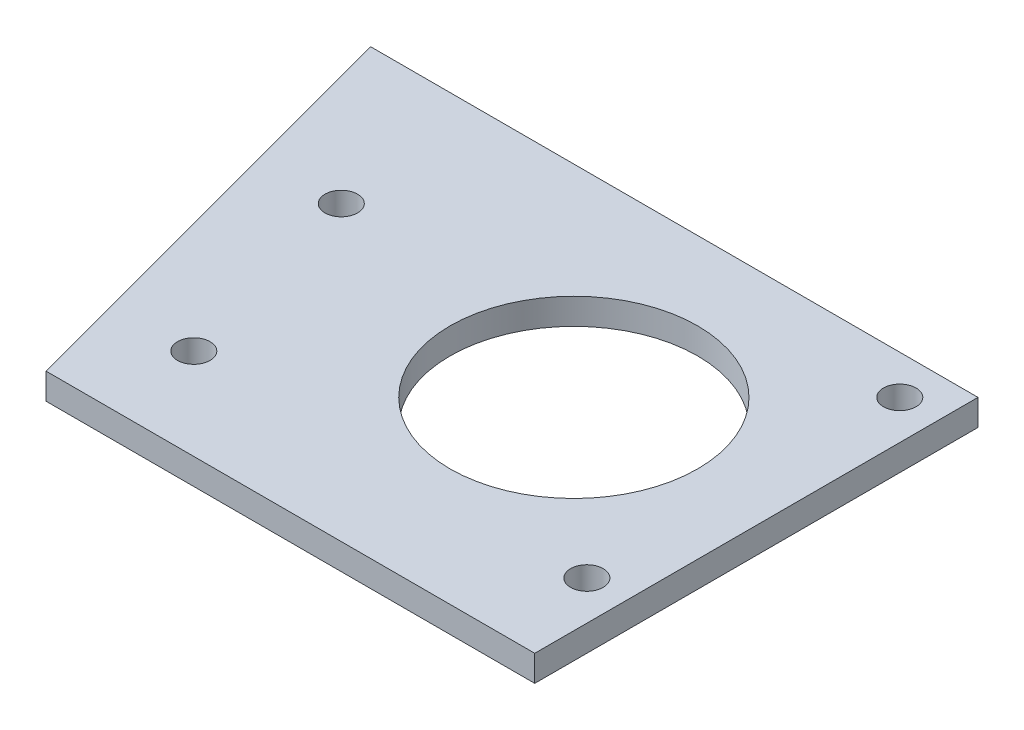
from build123d import *

# Parameters (mm, degrees)
SZKIC3_R                    = 47.5
SZKIC3_R_2                  = 6.25
DODANIE_WYCI_GNI_CIE2_DEPTH = 10


with BuildPart() as part:
    # Szkic3 → Dodanie-wyciągnięcie2 (new body)
    with BuildSketch(Plane(origin=(0, 0, 0), x_dir=(1, 0, 0), z_dir=(0, 1, 0))):
        Polygon((-77.5, 77.5), (77.5, 77.5), (77.5, -77.5), (77.5, -92.5), (-109.948637287, -92.5), (-155.5, 77.5), align=None)
        Circle(SZKIC3_R, mode=Mode.SUBTRACT)
        with Locations((62.5, 62.5)):
            Circle(SZKIC3_R_2, mode=Mode.SUBTRACT)
        with Locations((62.5, -57.5)):
            Circle(SZKIC3_R_2, mode=Mode.SUBTRACT)
        with Locations((-88.268573609, -57.5)):
            Circle(SZKIC3_R_2, mode=Mode.SUBTRACT)
        with Locations((-108.974097218, 19.774066103)):
            Circle(SZKIC3_R_2, mode=Mode.SUBTRACT)
    extrude(amount=DODANIE_WYCI_GNI_CIE2_DEPTH)


solid = part.part
